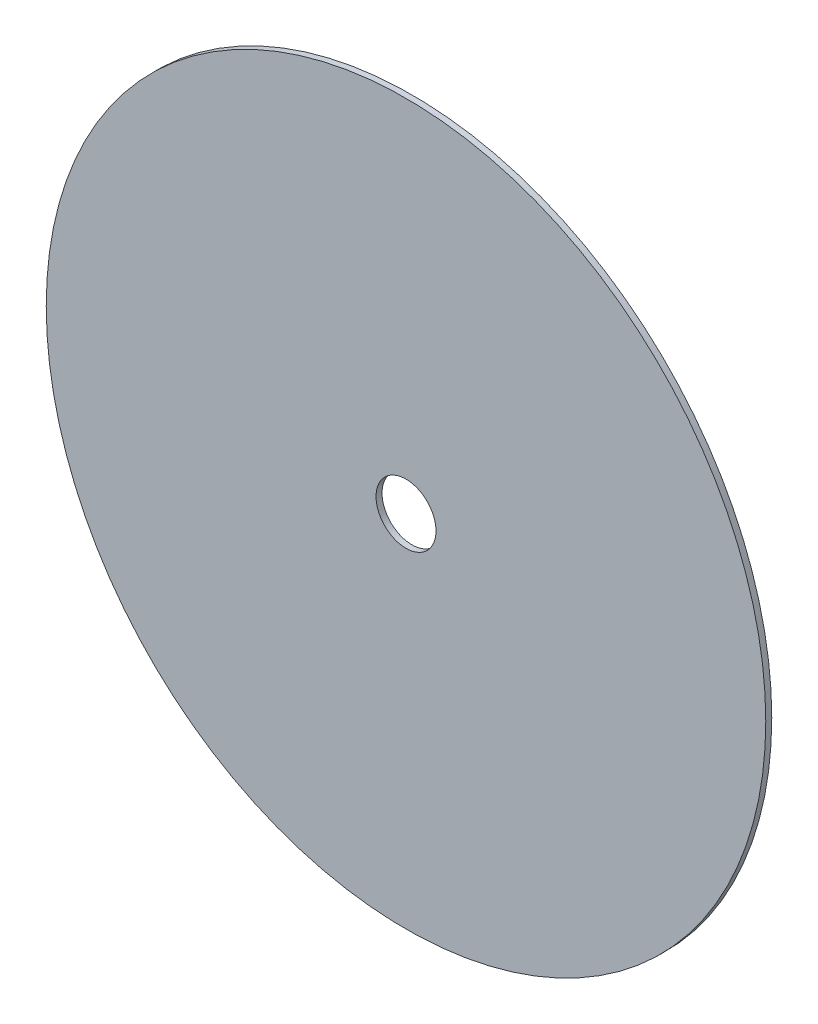
from build123d import *

# Parameters (mm, degrees)
SKETCH1_R           = 152.4
BOSS_EXTRUDE1_DEPTH = 2.54
SKETCH2_R           = 12.7
CUT_EXTRUDE1_DEPTH  = 3.54


with BuildPart() as part:
    # Sketch1 → Boss-Extrude1 (new body)
    with BuildSketch(Plane.XY):
        Circle(SKETCH1_R)
    extrude(amount=BOSS_EXTRUDE1_DEPTH)

    # Sketch2 → Cut-Extrude1 (cut, through all)
    with BuildSketch(Plane.XY.offset(2.54)):
        Circle(SKETCH2_R)
    extrude(amount=-CUT_EXTRUDE1_DEPTH, mode=Mode.SUBTRACT)


solid = part.part
